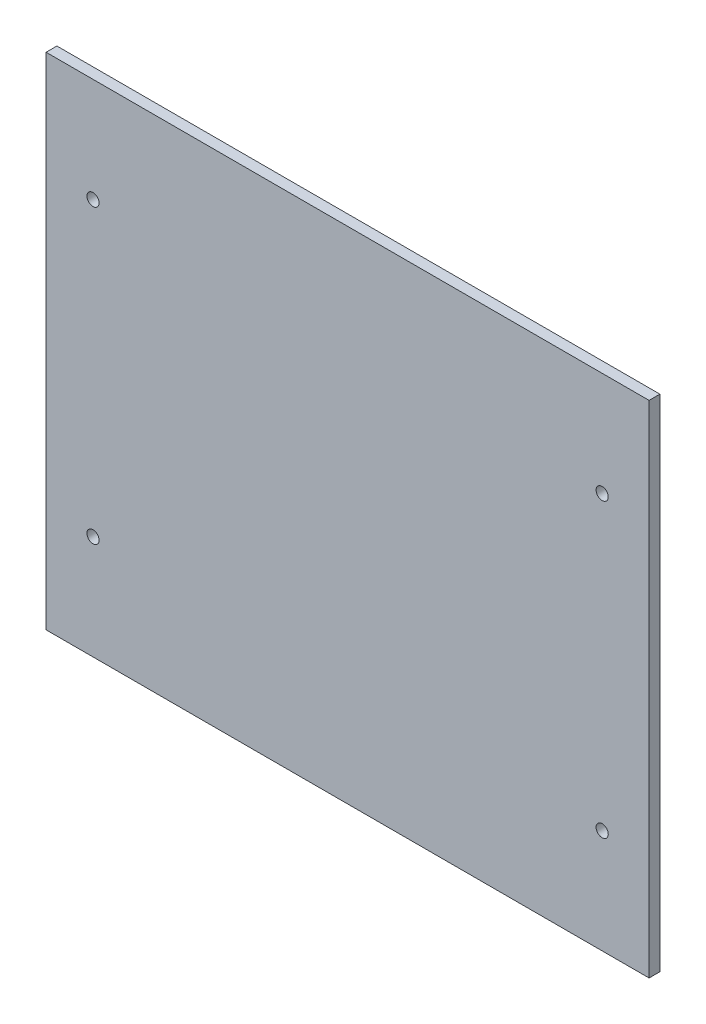
from build123d import *

# Parameters (mm, degrees)
SKETCH1_W           = 223
SKETCH1_H           = 185
SKETCH1_R           = 2.25
BOSS_EXTRUDE1_DEPTH = 4


with BuildPart() as part:
    # Sketch1 → Boss-Extrude1 (new body)
    with BuildSketch(Plane.XY):
        Rectangle(SKETCH1_W, SKETCH1_H)
        with Locations((-94.15, -54)):
            Circle(SKETCH1_R, mode=Mode.SUBTRACT)
        with Locations((94.15, -54)):
            Circle(SKETCH1_R, mode=Mode.SUBTRACT)
        with Locations((94.15, 54)):
            Circle(SKETCH1_R, mode=Mode.SUBTRACT)
        with Locations((-94.15, 54)):
            Circle(SKETCH1_R, mode=Mode.SUBTRACT)
    extrude(amount=BOSS_EXTRUDE1_DEPTH)


solid = part.part
